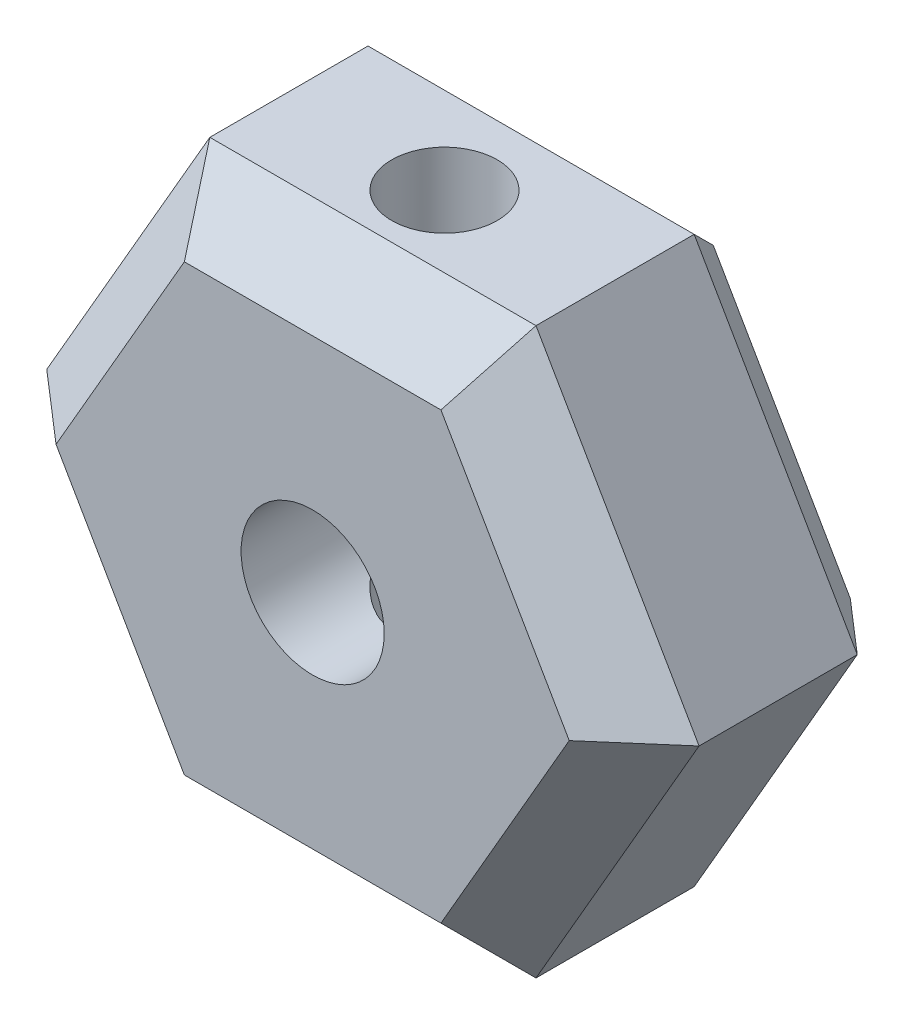
from build123d import *

# Parameters (mm, degrees)
SKETCH1_R           = 1.9
BOSS_EXTRUDE1_DEPTH = 7
SKETCH2_R           = 1.4
CUT_EXTRUDE1_DEPTH  = 16
CHAMFER1_SIZE       = 1.6
CHAMFER2_SIZE       = 1.2


with BuildPart() as part:
    # Sketch1 → Boss-Extrude1 (new body)
    with BuildSketch(Plane.XY):
        Polygon((8.660254038, 0), (4.330127019, 7.5), (-4.330127019, 7.5), (-8.660254038, 0), (-4.330127019, -7.5), (4.330127019, -7.5), align=None)
        Circle(SKETCH1_R, mode=Mode.SUBTRACT)
    extrude(amount=BOSS_EXTRUDE1_DEPTH)

    # Sketch2 → Cut-Extrude1 (cut, through all)
    with BuildSketch(Plane.XZ.offset(7.5)):
        with Locations((0, 3.5)):
            Circle(SKETCH2_R)
    extrude(amount=-CUT_EXTRUDE1_DEPTH, mode=Mode.SUBTRACT)

    # Chamfer1
    chamfer1_edges = [part.edges().sort_by_distance(p)[0] for p in [
        (0, 7.5, 7),
        (-6.495190528, 3.75, 7),
        (-6.495190528, -3.75, 7),
        (0, -7.5, 7),
        (6.495190528, -3.75, 7),
        (6.495190528, 3.75, 7),
    ]]
    chamfer(chamfer1_edges, length=CHAMFER1_SIZE)

    # Chamfer2
    chamfer2_edges = [part.edges().sort_by_distance(p)[0] for p in [
        (0, -7.5, 0),
        (-6.495190528, -3.75, 0),
        (-6.495190528, 3.75, 0),
        (0, 7.5, 0),
        (6.495190528, 3.75, 0),
        (6.495190528, -3.75, 0),
    ]]
    chamfer(chamfer2_edges, length=CHAMFER2_SIZE)


solid = part.part
